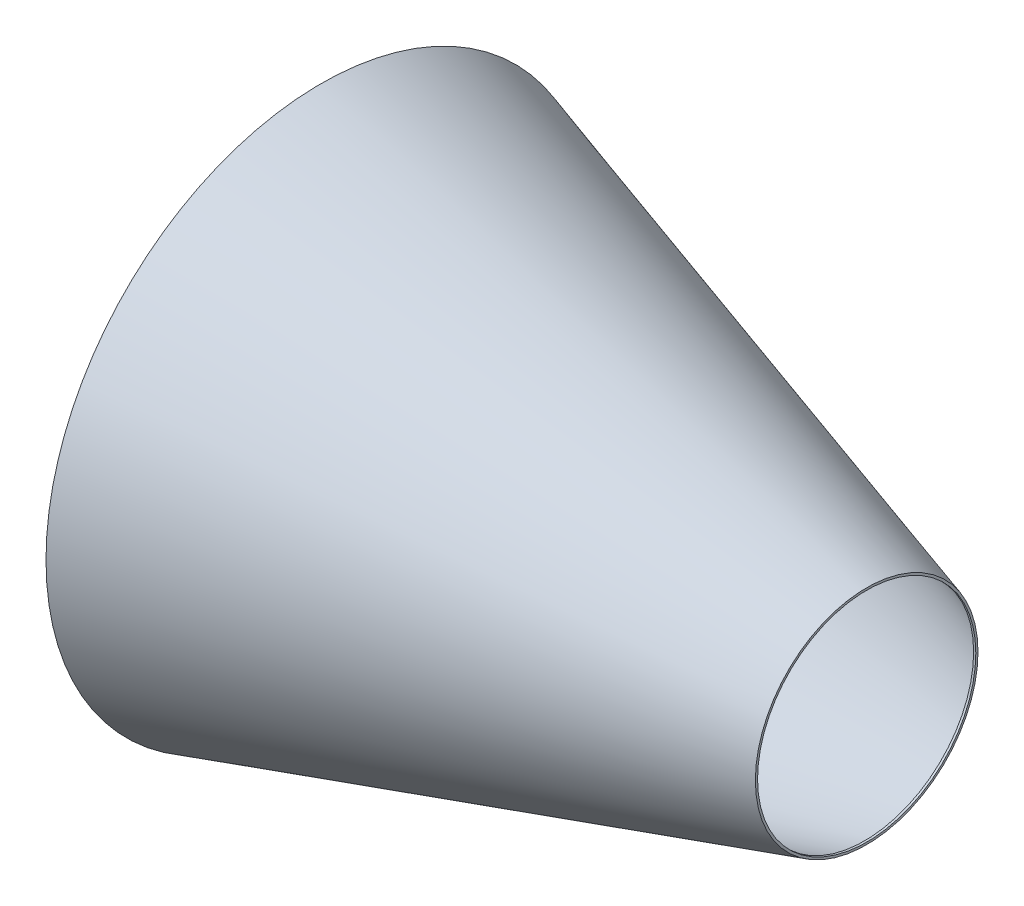
from build123d import *

# Parameters (mm, degrees)
SKETCH3_R          = 250
CUT_EXTRUDE7_DEPTH = 2
SKETCH6_R          = 2
CUT_EXTRUDE8_DEPTH = 498
SKETCH7_R          = 100
CUT_EXTRUDE9_DEPTH = 2


with BuildPart() as part:
    # Sketch2 → Revolve2 (revolve)
    with BuildSketch(Plane.XY):
        Polygon((0, 0), (0, -252), (500, -102), (500, 0), align=None)
        Polygon((2, -249.311938698), (498, -100.511938698), (498, -2), (2, -2), align=None, mode=Mode.SUBTRACT)
    revolve(axis=Axis((0, 0, 0), (1, 0, 0)))

    # Sketch3 → Cut-Extrude7 (cut)
    with BuildSketch(Plane.ZY):
        Circle(SKETCH3_R)
    extrude(amount=-CUT_EXTRUDE7_DEPTH, mode=Mode.SUBTRACT)

    # Sketch6 → Cut-Extrude8 (cut)
    with BuildSketch(Plane.ZY.offset(-2)):
        Circle(SKETCH6_R)
    extrude(amount=-CUT_EXTRUDE8_DEPTH, mode=Mode.SUBTRACT)

    # Sketch7 → Cut-Extrude9 (cut)
    with BuildSketch(Plane(origin=(500, 0, 0), x_dir=(0, 0, -1), z_dir=(1, 0, 0))):
        Circle(SKETCH7_R)
    extrude(amount=-CUT_EXTRUDE9_DEPTH, mode=Mode.SUBTRACT)


solid = part.part
